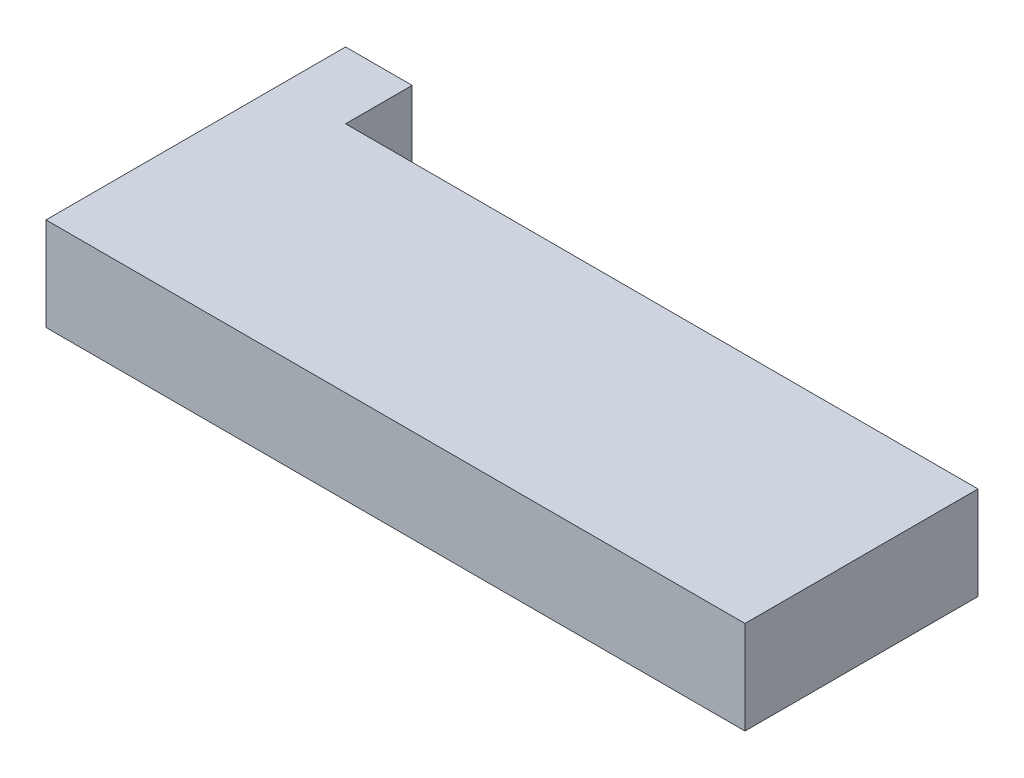
from build123d import *

# Parameters (mm, degrees)
SKETCH1_W           = 105
SKETCH1_H           = 35
BOSS_EXTRUDE1_DEPTH = 14
SKETCH2_W           = 10
SKETCH2_H           = 14
BOSS_EXTRUDE2_DEPTH = 10


with BuildPart() as part:
    # Sketch1 → Boss-Extrude1 (new body)
    with BuildSketch(Plane(origin=(0, 0, 0), x_dir=(1, 0, 0), z_dir=(0, 1, 0))):
        Rectangle(SKETCH1_W, SKETCH1_H)
    extrude(amount=BOSS_EXTRUDE1_DEPTH)

    # Sketch2 → Boss-Extrude2 (add)
    with BuildSketch(Plane(origin=(0, 0, -17.5), x_dir=(-1, 0, 0), z_dir=(0, 0, -1))):
        with Locations((47.5, 7)):
            Rectangle(SKETCH2_W, SKETCH2_H)
    extrude(amount=BOSS_EXTRUDE2_DEPTH)


solid = part.part
